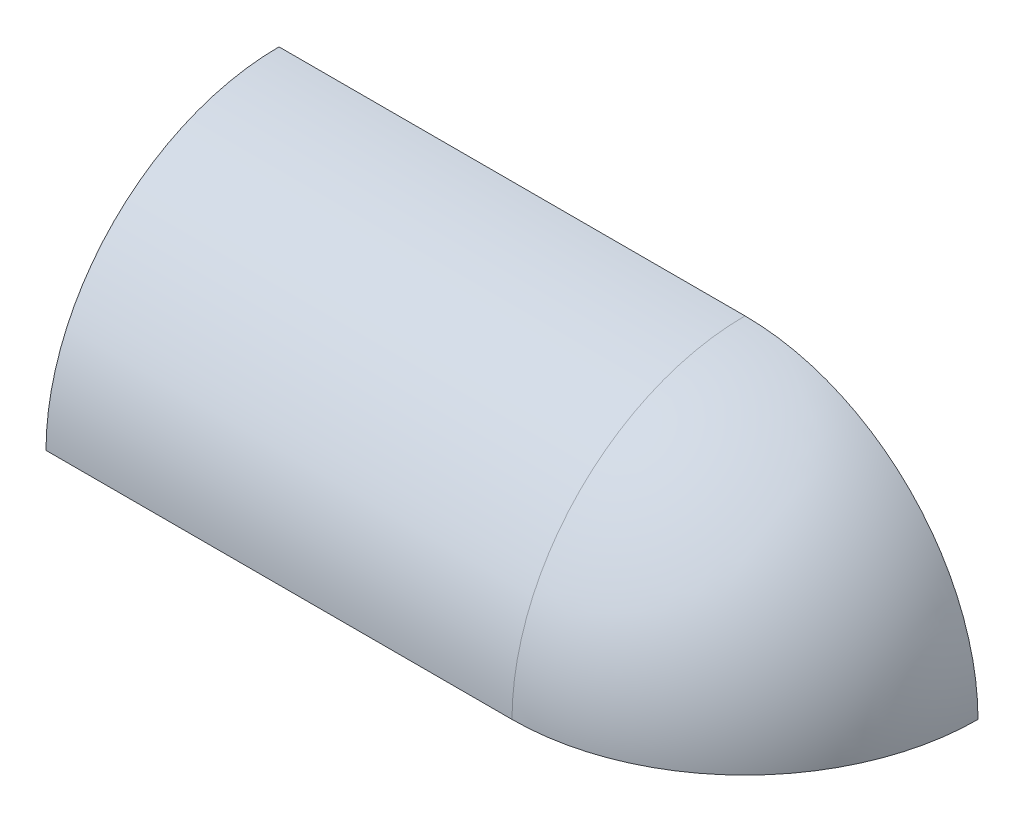
from build123d import *

# Parameters (mm, degrees)
SKETCH2_R           = 50.8
BOSS_EXTRUDE1_DEPTH = 101.6
SKETCH3_R           = 47.625
CUT_EXTRUDE1_DEPTH  = 101.6
SKETCH9_W           = 2921
SKETCH9_H           = 1905
CUT_EXTRUDE4_DEPTH  = 1828.8
SKETCH10_W          = 2914.398267979
SKETCH10_H          = 1269.930665489
CUT_EXTRUDE7_DEPTH  = 508
SKETCH11_W          = 281.911463331
SKETCH11_H          = 233.276474331
CUT_EXTRUDE8_DEPTH  = 153.4


with BuildPart() as part:
    # Sketch2 → Boss-Extrude1 (new body, symmetric)
    with BuildSketch(Plane(origin=(0, 0, 0), x_dir=(0, 0, -1), z_dir=(1, 0, 0))):
        Circle(SKETCH2_R)
    extrude(amount=BOSS_EXTRUDE1_DEPTH, both=True)

    # Sketch3 → Cut-Extrude1 (cut, symmetric)
    with BuildSketch(Plane(origin=(0, 0, 0), x_dir=(0, 0, -1), z_dir=(1, 0, 0))):
        Circle(SKETCH3_R)
    extrude(amount=CUT_EXTRUDE1_DEPTH, both=True, mode=Mode.SUBTRACT)

    # Sketch4 → Revolve-Thin1 (revolve)
    with BuildSketch(Plane.XY):
        with BuildLine():
            ThreePointArc((-101.6, 50.8), (-137.521024484, 35.921024484), (-152.4, 0))
            Line((-152.4, 0), (-149.225, 0))
            ThreePointArc((-149.225, 0), (-135.275960454, 33.675960454), (-101.6, 47.625))
            Line((-101.6, 47.625), (-101.6, 50.8))
        make_face()
    revolve(axis=Axis((-152.4, 0, 0), (1, 0, 0)))

    # Sketch5 → Revolve-Thin2 (revolve)
    with BuildSketch(Plane.XY):
        with BuildLine():
            ThreePointArc((101.6, 50.8), (137.521024484, 35.921024484), (152.4, 0))
            Line((152.4, 0), (149.225, 0))
            ThreePointArc((149.225, 0), (135.275960454, 33.675960454), (101.6, 47.625))
            Line((101.6, 47.625), (101.6, 50.8))
        make_face()
    revolve(axis=Axis((152.4, 0, 0), (-1, 0, 0)))

    # Sketch9 → Cut-Extrude4 (cut)
    with BuildSketch(Plane.XY):
        with Locations((975.277240458, -31.313733989)):
            Rectangle(SKETCH9_W, SKETCH9_H)
    extrude(amount=-CUT_EXTRUDE4_DEPTH, mode=Mode.SUBTRACT)

    # Sketch10 → Cut-Extrude7 (cut)
    with BuildSketch(Plane(origin=(0, 0, 0), x_dir=(1, 0, 0), z_dir=(0, 1, 0))):
        with Locations((902.969453076, -134.938526822)):
            Rectangle(SKETCH10_W, SKETCH10_H)
    extrude(amount=-CUT_EXTRUDE7_DEPTH, mode=Mode.SUBTRACT)

    # Sketch11 → Cut-Extrude8 (cut, through all)
    with BuildSketch(Plane(origin=(0, 0, 0), x_dir=(0, 0, -1), z_dir=(1, 0, 0))):
        with Locations((-43.809030365, 33.571989562)):
            Rectangle(SKETCH11_W, SKETCH11_H)
    extrude(amount=-CUT_EXTRUDE8_DEPTH, mode=Mode.SUBTRACT)


solid = part.part
